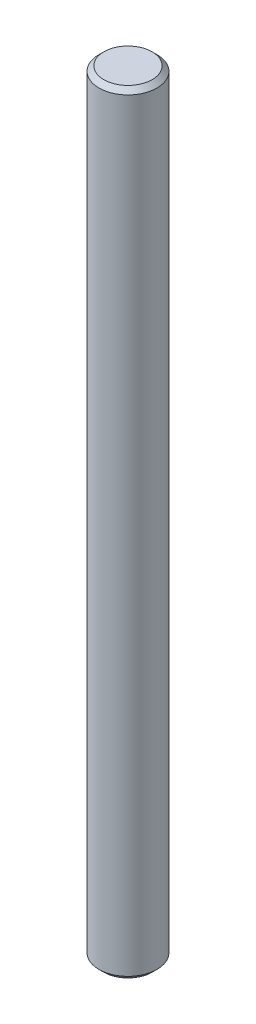
from build123d import *

# Parameters (mm, degrees)
SKETCH1_R           = 3
BOSS_EXTRUDE1_DEPTH = 80
CHAMFER1_SIZE       = 0.5


with BuildPart() as part:
    # Sketch1 → Boss-Extrude1 (new body)
    with BuildSketch(Plane(origin=(0, 0, 0), x_dir=(1, 0, 0), z_dir=(0, 1, 0))):
        Circle(SKETCH1_R)
    extrude(amount=BOSS_EXTRUDE1_DEPTH)

    # Chamfer1
    chamfer1_edges = [part.edges().sort_by_distance(p)[0] for p in [
        (-3, 0, 0),
        (-3, 80, 0),
    ]]
    chamfer(chamfer1_edges, length=CHAMFER1_SIZE)


solid = part.part
